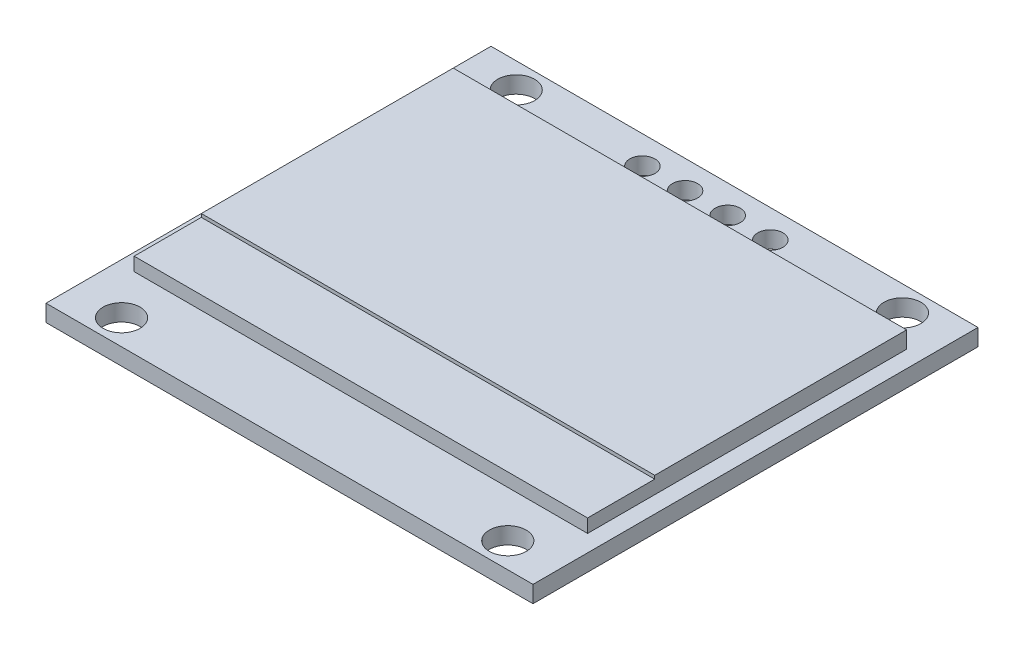
from build123d import *

# Parameters (mm, degrees)
SKETCH1_W           = 29
SKETCH1_H           = 26.5
BOSS_EXTRUDE1_DEPTH = 1
SKETCH2_R           = 1.1
CUT_EXTRUDE1_DEPTH  = 1
SKETCH3_W           = 27
SKETCH3_H           = 15
BOSS_EXTRUDE2_DEPTH = 1
SKETCH4_W           = 27
SKETCH4_H           = 19
BOSS_EXTRUDE3_DEPTH = 0.8
SKETCH5_R           = 0.75
CUT_EXTRUDE2_DEPTH  = 10.8


with BuildPart() as part:
    # Sketch1 → Boss-Extrude1 (new body)
    with BuildSketch(Plane(origin=(0, 0, 0), x_dir=(1, 0, 0), z_dir=(0, 1, 0))):
        with Locations((0, 0.5)):
            Rectangle(SKETCH1_W, SKETCH1_H)
    extrude(amount=BOSS_EXTRUDE1_DEPTH)

    # Sketch2 → Cut-Extrude1 (cut)
    with BuildSketch(Plane(origin=(0, 1, 0), x_dir=(1, 0, 0), z_dir=(0, 1, 0))):
        with Locations((-11.5, 12.25)):
            Circle(SKETCH2_R)
        with Locations((11.5, 12.25)):
            Circle(SKETCH2_R)
        with Locations((-11.5, -11.25)):
            Circle(SKETCH2_R)
        with Locations((11.5, -11.25)):
            Circle(SKETCH2_R)
    extrude(amount=-CUT_EXTRUDE1_DEPTH, mode=Mode.SUBTRACT)

    # Sketch3 → Boss-Extrude2 (add)
    with BuildSketch(Plane(origin=(0, 1, 0), x_dir=(1, 0, 0), z_dir=(0, 1, 0))):
        with Locations((0, 3)):
            Rectangle(SKETCH3_W, SKETCH3_H)
    extrude(amount=BOSS_EXTRUDE2_DEPTH)

    # Sketch4 → Boss-Extrude3 (add)
    with BuildSketch(Plane(origin=(0, 1, 0), x_dir=(1, 0, 0), z_dir=(0, 1, 0))):
        with Locations((0, 1)):
            Rectangle(SKETCH4_W, SKETCH4_H)
    extrude(amount=BOSS_EXTRUDE3_DEPTH)

    # Sketch5 → Cut-Extrude2 (cut)
    with BuildSketch(Plane(origin=(0, 1, 0), x_dir=(1, 0, 0), z_dir=(0, 1, 0))):
        with Locations((-1.27, 12.07364825)):
            Circle(SKETCH5_R)
        with Locations((1.27, 12.07364825)):
            Circle(SKETCH5_R)
        with Locations((3.81, 12.07364825)):
            Circle(SKETCH5_R)
        with Locations((-3.81, 12.07364825)):
            Circle(SKETCH5_R)
    extrude(amount=-CUT_EXTRUDE2_DEPTH, mode=Mode.SUBTRACT)


solid = part.part
